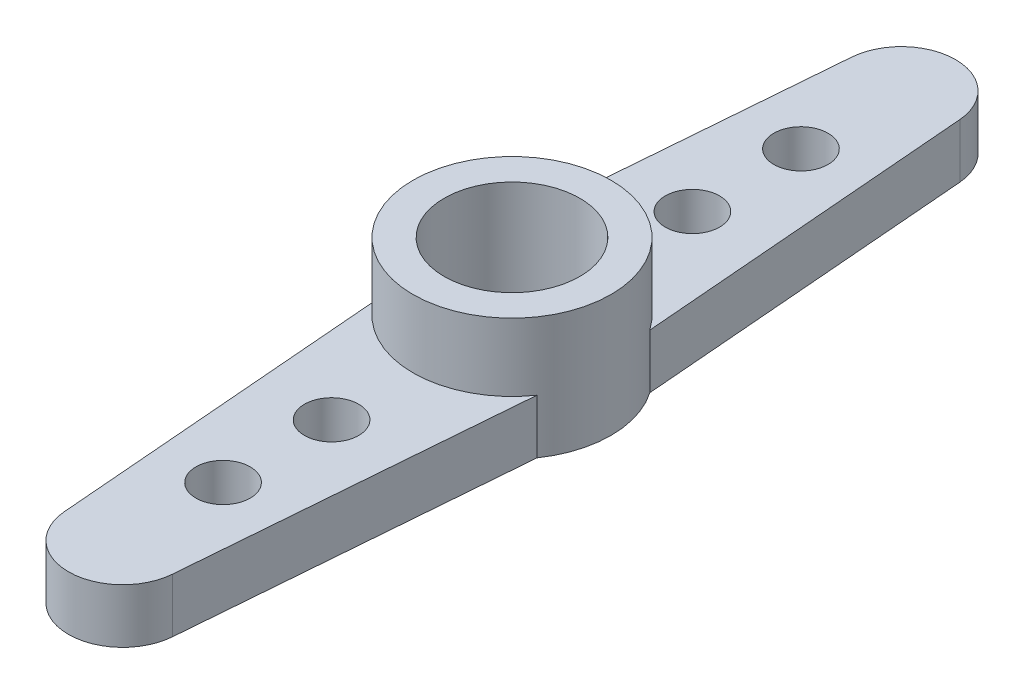
from build123d import *

# Parameters (mm, degrees)
SKETCH1_R           = 1
SKETCH1_R_2         = 2.5
BOSS_EXTRUDE1_DEPTH = 2
SKETCH2_R           = 3.65
SKETCH2_R_2         = 2.5
BOSS_EXTRUDE2_DEPTH = 2.5


with BuildPart() as part:
    # Sketch1 → Boss-Extrude1 (new body)
    with BuildSketch(Plane(origin=(0, 0, 0), x_dir=(1, 0, 0), z_dir=(0, 1, 0))):
        with BuildLine():
            Line((3, -2.079062289), (1.993477511, -14.51139211))
            ThreePointArc((1.993477511, -14.51139211), (0, -16.35), (-1.993477511, -14.51139211))
            Line((-1.993477511, -14.51139211), (-3, -2.079062289))
            ThreePointArc((-3, -2.079062289), (0, 3.65), (3, -2.079062289))
        make_face()
        with Locations((0, -6.65)):
            Circle(SKETCH1_R, mode=Mode.SUBTRACT)
        with Locations((0, -10.65)):
            Circle(SKETCH1_R, mode=Mode.SUBTRACT)
        Circle(SKETCH1_R_2, mode=Mode.SUBTRACT)
    boss_extrude1 = extrude(amount=BOSS_EXTRUDE1_DEPTH)

    # Sketch2 → Boss-Extrude2 (add)
    with BuildSketch(Plane(origin=(0, 2, 0), x_dir=(1, 0, 0), z_dir=(0, 1, 0))):
        Circle(SKETCH2_R)
        Circle(SKETCH2_R_2, mode=Mode.SUBTRACT)
    boss_extrude2 = extrude(amount=BOSS_EXTRUDE2_DEPTH)

    # Mirror1: Boss-Extrude1, Boss-Extrude2 across plane
    add(boss_extrude1.mirror(Plane.XY))
    add(boss_extrude2.mirror(Plane.XY))


solid = part.part
